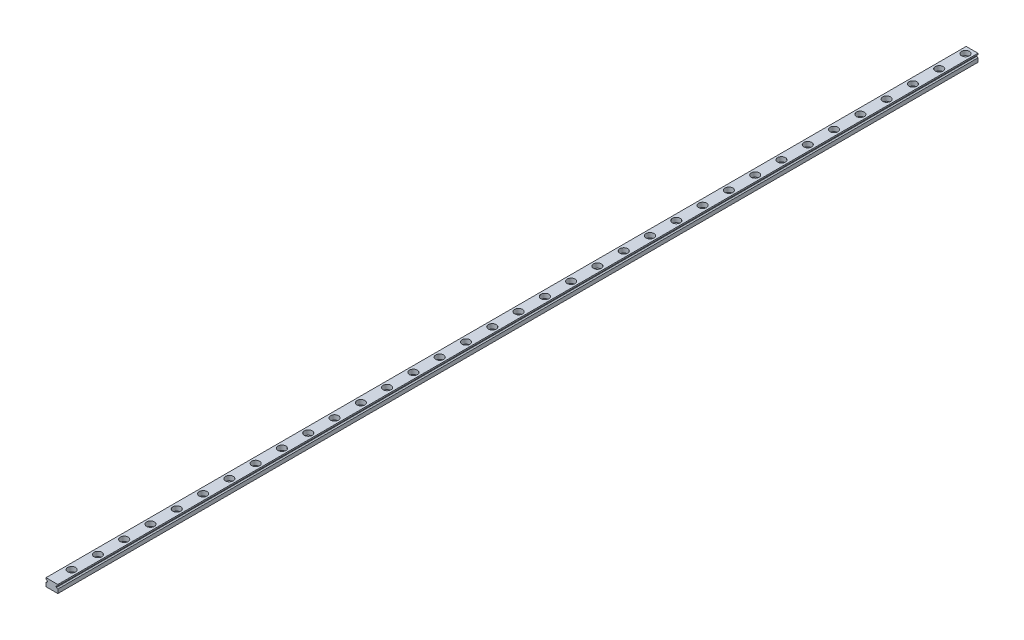
from build123d import *

# Parameters (mm, degrees)
EXTRUDE1_DEPTH  = 700
SKETCH2_R       = 3
EXTRUDE2_DEPTH  = 3.5
SKETCH_R        = 1.75
EXTRUDE3_DEPTH  = 701.040177418
LPATTERN1_COUNT = 45
LPATTERN1_PITCH = 20


with BuildPart() as part:
    # Sketch1 → Extrude1 (new body)
    with BuildSketch(Plane.XY):
        with BuildLine():
            Line((-4.5, -3), (4.5, -3))
            Line((4.5, -3), (4.5, 0))
            ThreePointArc((4.5, 0), (3.93077967, 0.177814974), (3.563991137, 0.648023568))
            Line((3.563991137, 0.648023568), (3.235073025, 0.648023568))
            Line((3.235073025, 0.648023568), (3.235073025, 1.351976432))
            Line((3.235073025, 1.351976432), (3.563991137, 1.351976432))
            ThreePointArc((3.563991137, 1.351976432), (3.93077967, 1.822185026), (4.5, 2))
            Line((4.5, 2), (4.5, 3))
            Line((4.5, 3), (-4.5, 3))
            Line((-4.5, 3), (-4.5, 2))
            ThreePointArc((-4.5, 2), (-3.93077967, 1.822185026), (-3.563991137, 1.351976432))
            Line((-3.563991137, 1.351976432), (-3.235073025, 1.351976432))
            Line((-3.235073025, 1.351976432), (-3.235073025, 0.648023568))
            Line((-3.235073025, 0.648023568), (-3.563991137, 0.648023568))
            ThreePointArc((-3.563991137, 0.648023568), (-3.93077967, 0.177814974), (-4.5, 0))
            Line((-4.5, 0), (-4.5, -3))
        make_face()
    extrude(amount=EXTRUDE1_DEPTH)

    # Sketch2 → Extrude2 (cut)
    with BuildSketch(Plane(origin=(0, 3, 0), x_dir=(1, 0, 0), z_dir=(0, 1, 0))):
        with Locations((0, -5)):
            Circle(SKETCH2_R)
    extrude2 = extrude(amount=-EXTRUDE2_DEPTH, mode=Mode.SUBTRACT)

    # Sketch → Extrude3 (cut, through all)
    with BuildSketch(Plane(origin=(0, 3, 0), x_dir=(1, 0, 0), z_dir=(0, 1, 0))):
        with Locations((0, -5)):
            Circle(SKETCH_R)
    extrude3 = extrude(amount=-EXTRUDE3_DEPTH, mode=Mode.SUBTRACT)

    # LPattern1: Extrude2, Extrude3 ×45
    with Locations(*[(0, 0, i * LPATTERN1_PITCH) for i in range(1, LPATTERN1_COUNT)]):
        add(extrude2, mode=Mode.SUBTRACT)
        add(extrude3, mode=Mode.SUBTRACT)


solid = part.part
